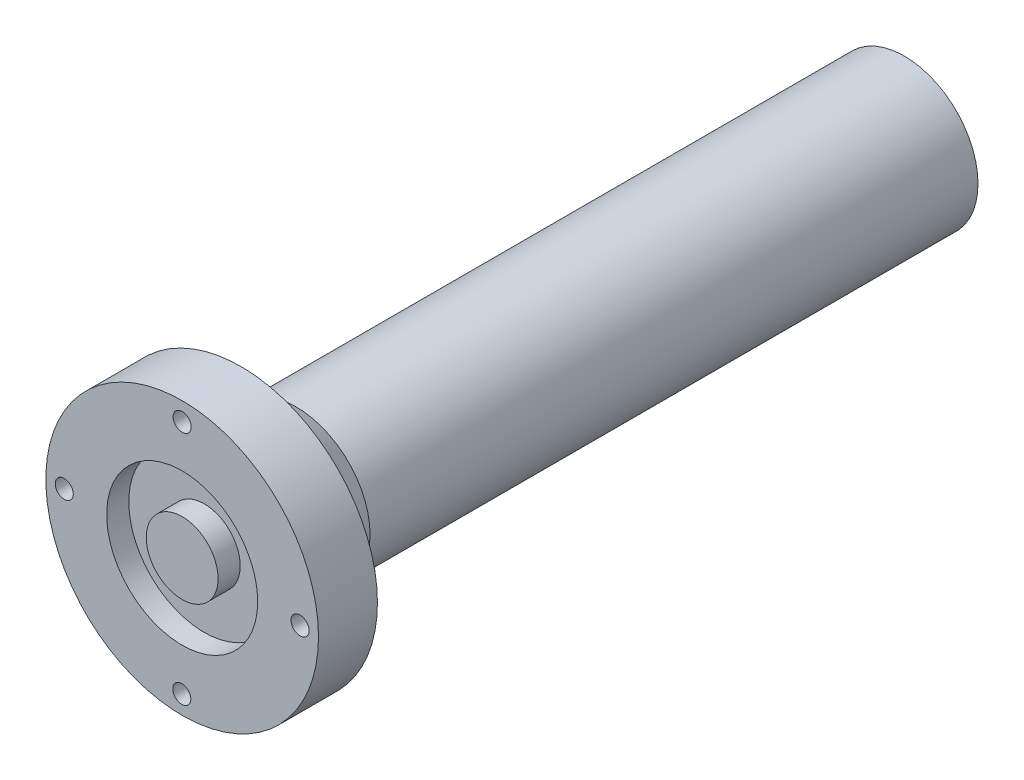
from build123d import *

# Parameters (mm, degrees)
SKETCH_1_R          = 20
EXTRUDE_1_DEPTH     = 180
SKETCH_3_R          = 37
EXTRUDE_3_DEPTH     = 16
SKETCH_4_R          = 20.5
CUT_EXTRUDE_1_DEPTH = 6
SKETCH_5_R          = 9.75
EXTRUDE_4_DEPTH     = 6
CUT_EXTRUDE_3_REACH = 198
SKETCH_10_R         = 2.45
SKETCH_18_R         = 4.4
CUT_EXTRUDE_4_DEPTH = 5


with BuildPart() as part:
    # 스케치1 → 보스-돌출1 (new body)
    with BuildSketch(Plane.XY):
        Circle(SKETCH_1_R)
    extrude(amount=EXTRUDE_1_DEPTH)

    # 스케치3 → 보스-돌출3 (add)
    with BuildSketch(Plane.XY.offset(180)):
        Circle(SKETCH_3_R)
    extrude(amount=EXTRUDE_3_DEPTH)

    # 스케치4 → 컷-돌출1 (cut)
    with BuildSketch(Plane.XY.offset(196)):
        Circle(SKETCH_4_R)
    extrude(amount=-CUT_EXTRUDE_1_DEPTH, mode=Mode.SUBTRACT)

    # 스케치5 → 보스-돌출4 (add)
    with BuildSketch(Plane.XY.offset(190)):
        Circle(SKETCH_5_R)
    extrude(amount=EXTRUDE_4_DEPTH)

    # 스케치10 → 컷-돌출3 (cut, up to next)
    with BuildSketch(Plane.XY.offset(196), mode=Mode.PRIVATE) as cut_extrude_3_sk1:
        with Locations((0, 32)):
            Circle(SKETCH_10_R)
    cut_extrude_3_tool1 = extrude(cut_extrude_3_sk1.sketch, amount=-CUT_EXTRUDE_3_REACH, mode=Mode.PRIVATE) & part.part
    add(cut_extrude_3_tool1.solids().sort_by_distance((0, 32, 196))[0], mode=Mode.SUBTRACT)
    # 스케치10 → 컷-돌출3 (cut, up to next)
    with BuildSketch(Plane.XY.offset(196), mode=Mode.PRIVATE) as cut_extrude_3_sk2:
        with Locations((32, 0.150294809)):
            Circle(SKETCH_10_R)
    cut_extrude_3_tool2 = extrude(cut_extrude_3_sk2.sketch, amount=-CUT_EXTRUDE_3_REACH, mode=Mode.PRIVATE) & part.part
    add(cut_extrude_3_tool2.solids().sort_by_distance((32, 0.150295, 196))[0], mode=Mode.SUBTRACT)
    # 스케치10 → 컷-돌출3 (cut, up to next)
    with BuildSketch(Plane.XY.offset(196), mode=Mode.PRIVATE) as cut_extrude_3_sk3:
        with Locations((-32, 0.258434211)):
            Circle(SKETCH_10_R)
    cut_extrude_3_tool3 = extrude(cut_extrude_3_sk3.sketch, amount=-CUT_EXTRUDE_3_REACH, mode=Mode.PRIVATE) & part.part
    add(cut_extrude_3_tool3.solids().sort_by_distance((-32, 0.258434, 196))[0], mode=Mode.SUBTRACT)
    # 스케치10 → 컷-돌출3 (cut, up to next)
    with BuildSketch(Plane.XY.offset(196), mode=Mode.PRIVATE) as cut_extrude_3_sk4:
        with Locations((-0.108139402, -32)):
            Circle(SKETCH_10_R)
    cut_extrude_3_tool4 = extrude(cut_extrude_3_sk4.sketch, amount=-CUT_EXTRUDE_3_REACH, mode=Mode.PRIVATE) & part.part
    add(cut_extrude_3_tool4.solids().sort_by_distance((-0.108139, -32, 196))[0], mode=Mode.SUBTRACT)

    # 스케치18 → 컷-돌출4 (cut)
    with BuildSketch(Plane(origin=(0, 0, 180), x_dir=(-1, 0, 0), z_dir=(0, 0, -1))):
        with Locations((0, 32)):
            Circle(SKETCH_18_R)
        with Locations((32, 0.258434211)):
            Circle(SKETCH_18_R)
        with Locations((0.108139402, -32)):
            Circle(SKETCH_18_R)
        with Locations((-32, 0.150294809)):
            Circle(SKETCH_18_R)
    extrude(amount=-CUT_EXTRUDE_4_DEPTH, mode=Mode.SUBTRACT)

    # 스케치20 → 회전1 (revolve)
    with BuildSketch(Plane(origin=(0, 0, 0), x_dir=(1, 0, 0), z_dir=(0, 1, 0))):
        Polygon((-20, -180), (-27.6, -180), (-20, -165), align=None)
    revolve(axis=Axis((0, 0, 180), (0, 0, -1)))


solid = part.part
